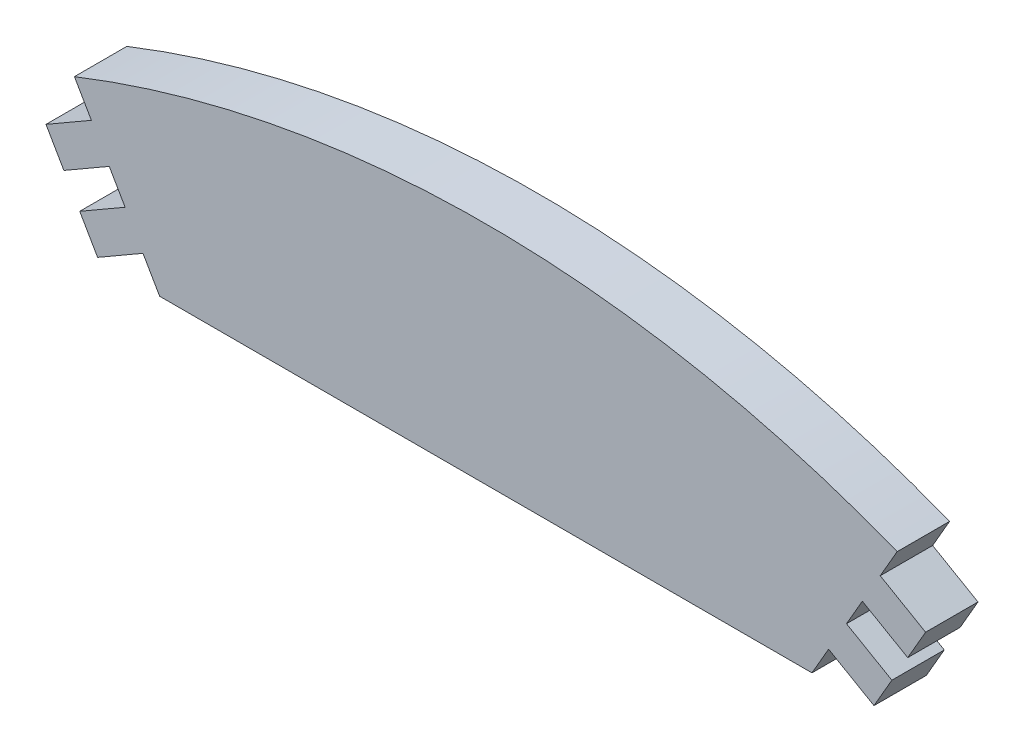
from build123d import *

# Parameters (mm, degrees)
BOSS_EXTRUDE1_DEPTH = 5.15


with BuildPart() as part:
    # Sketch1 → Boss-Extrude1 (new body)
    with BuildSketch(Plane.XY):
        with BuildLine():
            Line((-32.057735027, 87.9), (32.057735027, 87.9))
            Line((32.057735027, 87.9), (33.694332379, 90.734669766))
            Line((33.694332379, 90.734669766), (38.154363209, 88.159669766))
            Line((38.154363209, 88.159669766), (39.912093048, 91.204147153))
            Line((39.912093048, 91.204147153), (35.452062218, 93.779147153))
            Line((35.452062218, 93.779147153), (37.009792057, 96.477214379))
            Line((37.009792057, 96.477214379), (41.469822887, 93.902214379))
            Line((41.469822887, 93.902214379), (43.227552726, 96.946691766))
            Line((43.227552726, 96.946691766), (38.767521896, 99.521691766))
            Line((38.767521896, 99.521691766), (40.433263841, 102.406841447))
            ThreePointArc((40.433263841, 102.406841447), (0, 110.1), (-40.433263841, 102.406841447))
            Line((-40.433263841, 102.406841447), (-38.767521896, 99.521691766))
            Line((-38.767521896, 99.521691766), (-43.227552726, 96.946691766))
            Line((-43.227552726, 96.946691766), (-41.469822887, 93.902214379))
            Line((-41.469822887, 93.902214379), (-37.009792057, 96.477214379))
            Line((-37.009792057, 96.477214379), (-35.452062218, 93.779147153))
            Line((-35.452062218, 93.779147153), (-39.912093048, 91.204147153))
            Line((-39.912093048, 91.204147153), (-38.154363209, 88.159669766))
            Line((-38.154363209, 88.159669766), (-33.694332379, 90.734669766))
            Line((-33.694332379, 90.734669766), (-32.057735027, 87.9))
        make_face()
    extrude(amount=BOSS_EXTRUDE1_DEPTH)


solid = part.part
